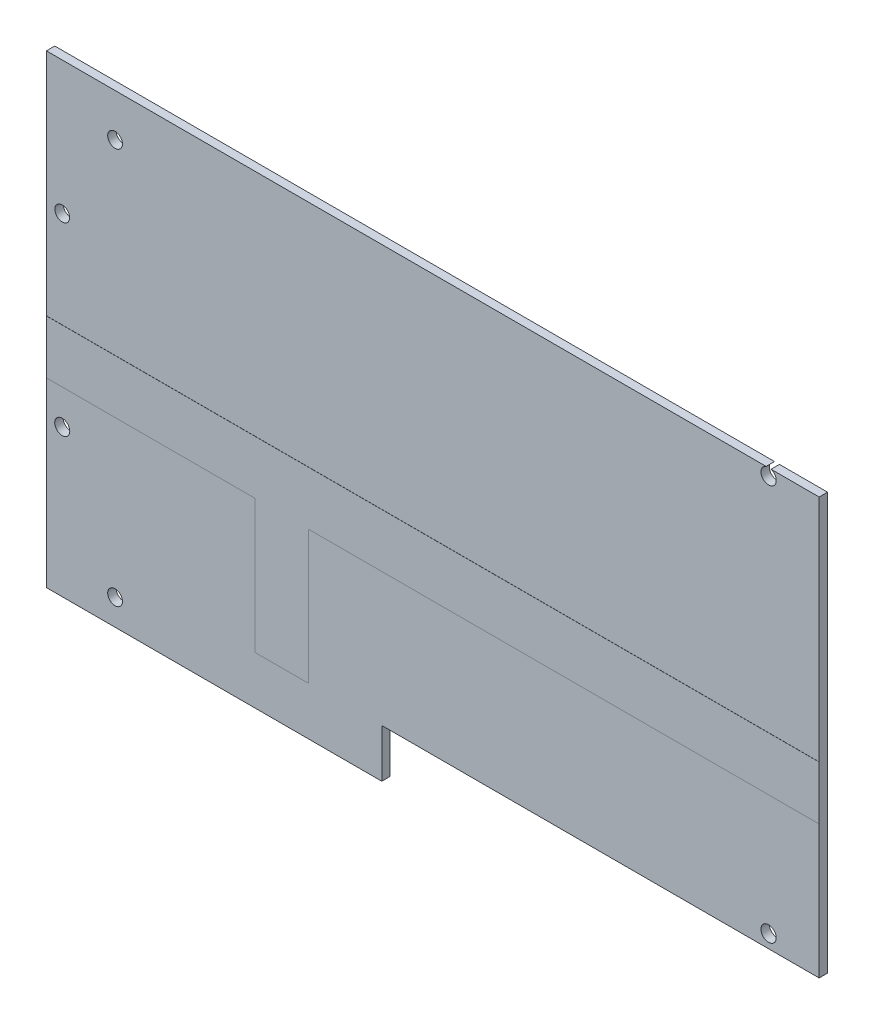
from build123d import *

# Parameters (mm, degrees)
SKETCH1_W                = 146.304
SKETCH1_H                = 78.867
BOSS_EXTRUDE1_DEPTH      = 1.5875
BOSS_EXTRUDE2_DEPTH      = 0.0254
BOSS_EXTRUDE2_DEPTH_BACK = 1.6254
SKETCH5_R                = 1.445
CUT_EXTRUDE1_DEPTH       = 2.6254
SKETCH7_W                = 63.5
SKETCH7_H                = 9.144
BOSS_EXTRUDE3_DEPTH      = 1.5875
SKETCH6_R                = 1.397
SKETCH6_R_2              = 1.425015072
CUT_EXTRUDE2_DEPTH       = 2.6254


with BuildPart() as part:
    # Sketch1 → Boss-Extrude1 (new body)
    with BuildSketch(Plane.XY):
        with Locations((0, 9.0805)):
            Rectangle(SKETCH1_W, SKETCH1_H)
    extrude(amount=BOSS_EXTRUDE1_DEPTH)

    # Sketch4 → Boss-Extrude2 (add, two sides)
    with BuildSketch(Plane.XY.offset(1.5875)) as boss_extrude2_sk:
        Polygon((-73.152, 5.08), (73.152, 5.08), (73.152, -5.08), (-23.4823, -5.08), (-23.4823, -30.353), (-33.6423, -30.353), (-33.6423, -5.08), (-73.152, -5.08), align=None)
    extrude(amount=BOSS_EXTRUDE2_DEPTH)
    extrude(boss_extrude2_sk.sketch, amount=-BOSS_EXTRUDE2_DEPTH_BACK)

    # Sketch5 → Cut-Extrude1 (cut, through all)
    with BuildSketch(Plane.XY.offset(1.5875)):
        with Locations((63.58, 47.147)):
            Circle(SKETCH5_R)
        with Locations((63.58, -27.853)):
            Circle(SKETCH5_R)
    extrude(amount=-CUT_EXTRUDE1_DEPTH, mode=Mode.SUBTRACT)

    # Sketch7 → Boss-Extrude3 (add)
    with BuildSketch(Plane.XY.offset(1.5875)):
        with Locations((-41.402, -34.925)):
            Rectangle(SKETCH7_W, SKETCH7_H)
    extrude(amount=-BOSS_EXTRUDE3_DEPTH)

    # Sketch6 → Cut-Extrude2 (cut, through all)
    with BuildSketch(Plane.XY.offset(1.5875)):
        with Locations((-70.152, 23.35)):
            Circle(SKETCH6_R)
        with Locations((-70.152, -11.65)):
            Circle(SKETCH6_R_2)
        with Locations((-60.152, 40.424999886)):
            Circle(SKETCH6_R)
        with Locations((-60.152, -34.575)):
            Circle(SKETCH6_R)
    extrude(amount=-CUT_EXTRUDE2_DEPTH, mode=Mode.SUBTRACT)


solid = part.part
